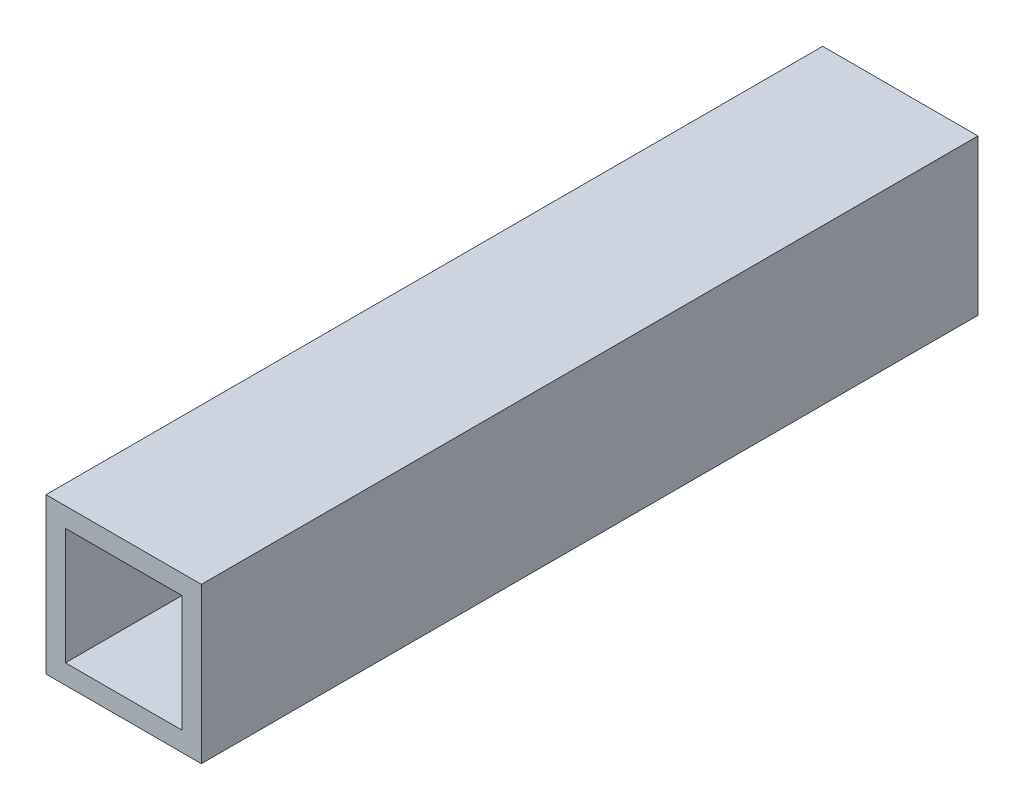
from build123d import *

# Parameters (mm, degrees)
SKETCH1_W           = 25.4
SKETCH1_H           = 25.4
BOSS_EXTRUDE1_DEPTH = 127
CUT_EXTRUDE1_DEPTH  = 127


with BuildPart() as part:
    # Sketch1 → Boss-Extrude1 (new body)
    with BuildSketch(Plane.XY):
        Rectangle(SKETCH1_W, SKETCH1_H)
    extrude(amount=BOSS_EXTRUDE1_DEPTH)

    # 3DSketch1 → Cut-Extrude1 (cut)
    with BuildSketch(Plane(origin=(-9.525, -9.525, 127), x_dir=(0.7071067811865475, 0.7071067811865476, 0), z_dir=(0, 0, -1))):
        Polygon((0, 0), (13.470384182, 13.470384182), (26.940768363, 0), (13.470384182, -13.470384182), align=None)
    extrude(amount=CUT_EXTRUDE1_DEPTH, mode=Mode.SUBTRACT)


solid = part.part
